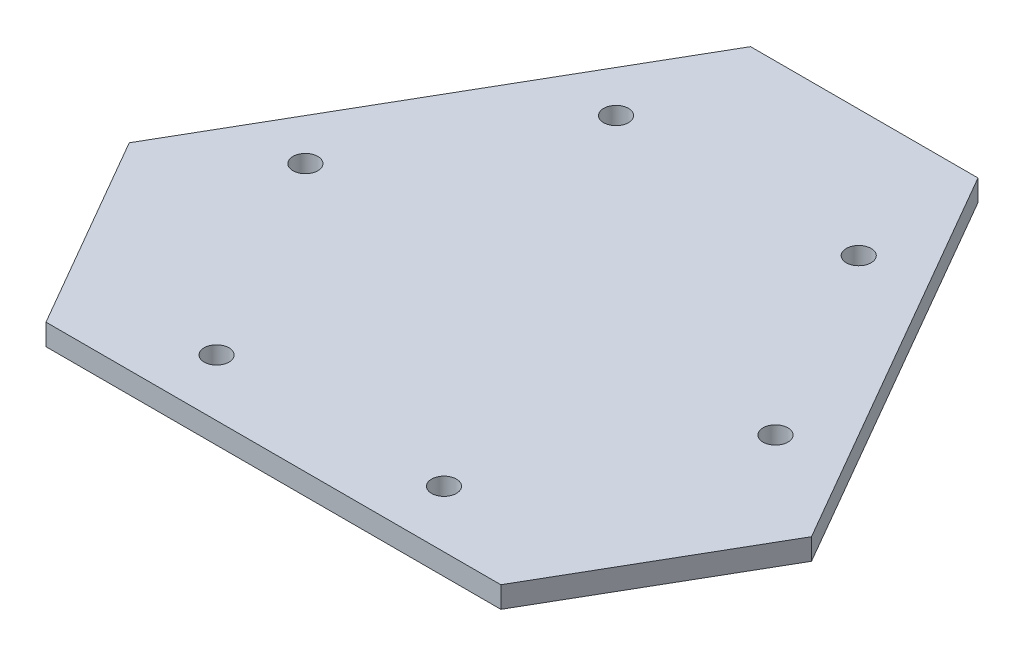
from build123d import *

# Parameters (mm, degrees)
BOSS_EXTRUDE1_DEPTH = 4.7625
SKETCH2_R           = 5.55625
CUT_EXTRUDE1_DEPTH  = 212.711641055
CIRPATTERN1_COUNT   = 3


with BuildPart() as part:
    # Sketch1 → Boss-Extrude1 (new, symmetric)
    with BuildSketch(Plane(origin=(0, 0, 0), x_dir=(1, 0, 0), z_dir=(0, 1, 0))):
        Polygon((-50.8, 146.646968374), (50.8, 146.646968374), (152.4, -29.329393675), (101.6, -117.317574699), (-101.6, -117.317574699), (-152.4, -29.329393675), align=None)
    extrude(amount=BOSS_EXTRUDE1_DEPTH, both=True)

    # Sketch2 → Cut-Extrude1 (cut, through all)
    with BuildSketch(Plane(origin=(0, 4.7625, 0), x_dir=(1, 0, 0), z_dir=(0, 1, 0))):
        with Locations((105.002954744, 1.964696837)):
            Circle(SKETCH2_R)
        with Locations((54.202954744, 89.952877862)):
            Circle(SKETCH2_R)
    cut_extrude1 = extrude(amount=-CUT_EXTRUDE1_DEPTH, mode=Mode.SUBTRACT)

    # CirPattern1: Cut-Extrude1 ×3 about axis
    cirpattern1_axis = Axis((0, 5.23875, 0), (0, -1, 0))
    for i in range(1, CIRPATTERN1_COUNT):
        add(cut_extrude1.rotate(cirpattern1_axis, i * 360 / CIRPATTERN1_COUNT), mode=Mode.SUBTRACT)


solid = part.part
